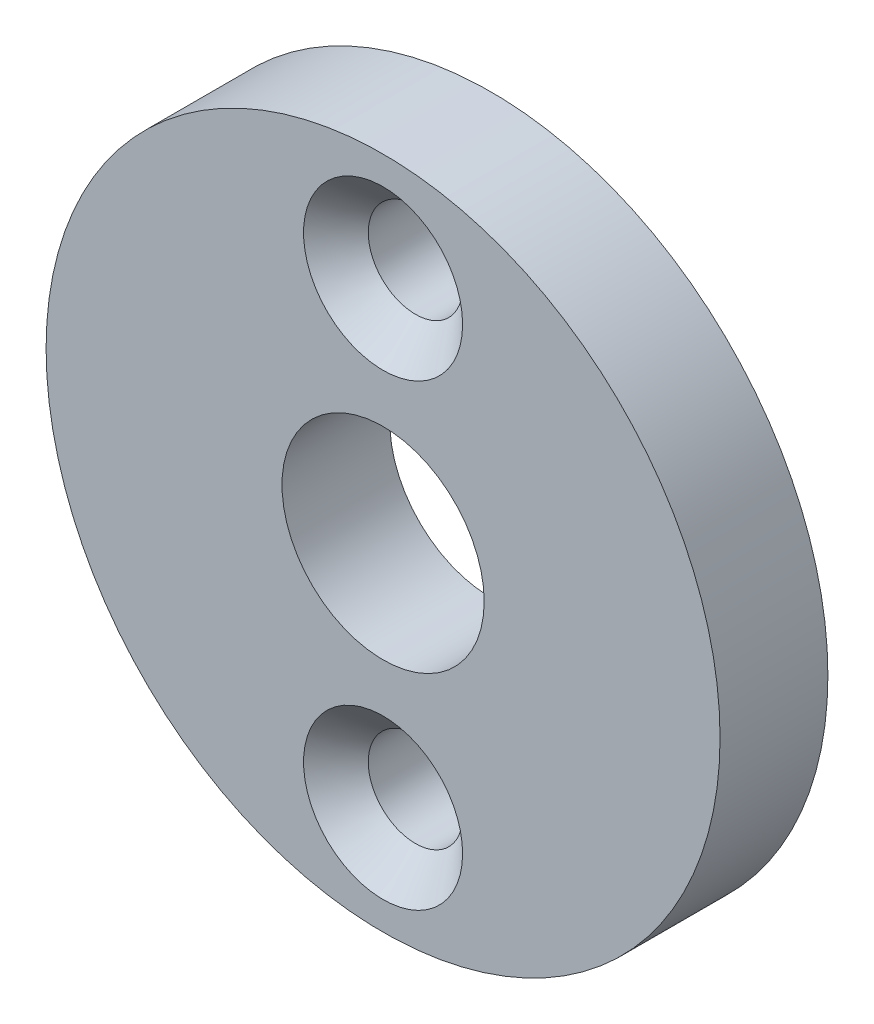
from build123d import *

# Parameters (mm, degrees)
SKETCH1_R           = 12.5
SKETCH1_R_2         = 1.75
SKETCH1_R_3         = 3.75
BOSS_EXTRUDE1_DEPTH = 4
CHAMFER2_SIZE       = 1.2


with BuildPart() as part:
    # Sketch1 → Boss-Extrude1 (new body)
    with BuildSketch(Plane.XY):
        with Locations((30.875, 0)):
            Circle(SKETCH1_R)
        with Locations((30.875, 8.5)):
            Circle(SKETCH1_R_2, mode=Mode.SUBTRACT)
        with Locations((30.875, -8.5)):
            Circle(SKETCH1_R_2, mode=Mode.SUBTRACT)
        with Locations((30.875, 0)):
            Circle(SKETCH1_R_3, mode=Mode.SUBTRACT)
    extrude(amount=BOSS_EXTRUDE1_DEPTH)

    # Chamfer2
    chamfer2_edges = [part.edges().sort_by_distance(p)[0] for p in [
        (29.125, 8.5, 4),
        (29.125, -8.5, 4),
    ]]
    chamfer(chamfer2_edges, length=CHAMFER2_SIZE)


solid = part.part
